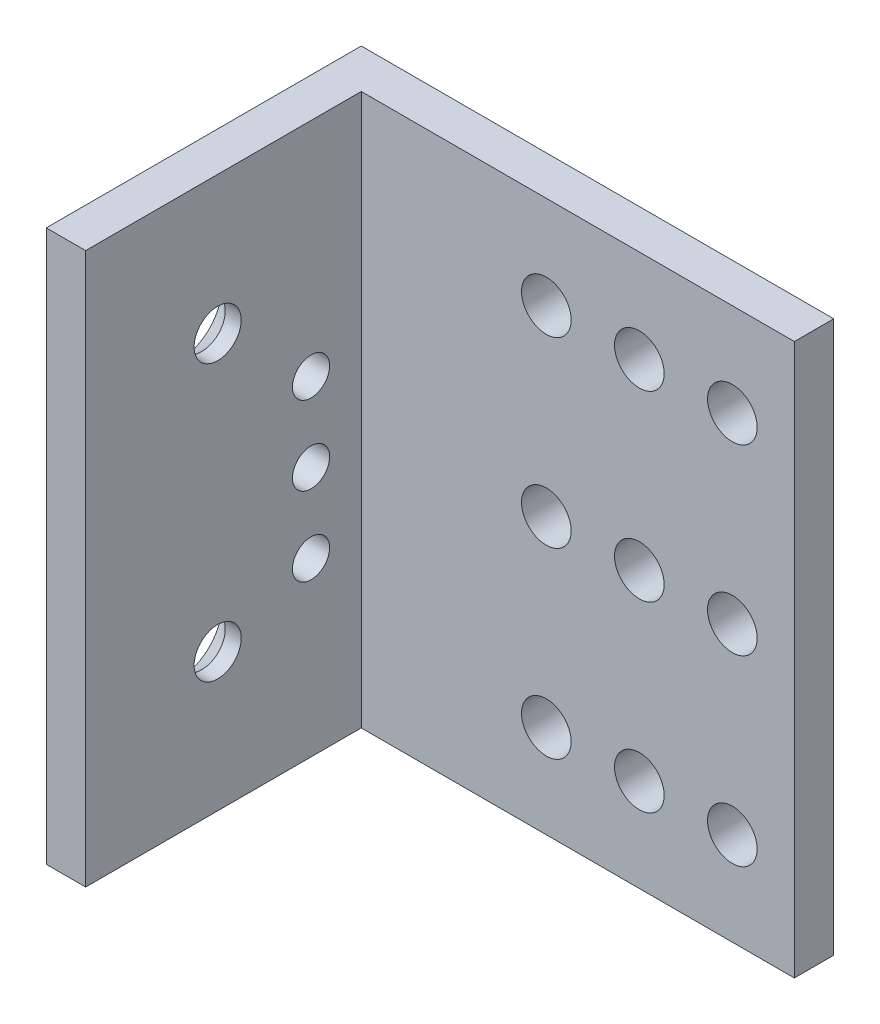
from build123d import *

# Parameters (mm, degrees)
BOSS_EXTRUDE1_DEPTH                            = 22.225
CSK_FOR_6_FLAT_HEAD_MACHINE_SCREW1_D           = 3.7973
CSK_FOR_6_FLAT_HEAD_MACHINE_SCREW1_CSINK_D     = 7.0866
CSK_FOR_6_FLAT_HEAD_MACHINE_SCREW1_CSINK_ANGLE = 82
SKETCH6_R                                      = 2
CUT_EXTRUDE2_DEPTH                             = 26.4
SKETCH7_R                                      = 1.5
CUT_EXTRUDE3_DEPTH                             = 4.175


with BuildPart() as part:
    # Sketch1 → Boss-Extrude1 (new body, symmetric)
    with BuildSketch(Plane(origin=(0, 0, 0), x_dir=(1, 0, 0), z_dir=(0, 1, 0))):
        Polygon((-19.05, -12.7), (-15.875, -12.7), (-15.875, 9.525), (19.05, 9.525), (19.05, 12.7), (-19.05, 12.7), align=None)
    extrude(amount=BOSS_EXTRUDE1_DEPTH, both=True)

    # CSK for #6 Flat Head Machine Screw1 (through all)
    with Locations(Plane.ZY.offset(19.05)):
        with Locations((2.055, 11.1125)):
            csk_for_6_flat_head_machine_screw1 = CounterSinkHole(CSK_FOR_6_FLAT_HEAD_MACHINE_SCREW1_D / 2, CSK_FOR_6_FLAT_HEAD_MACHINE_SCREW1_CSINK_D / 2, counter_sink_angle=CSK_FOR_6_FLAT_HEAD_MACHINE_SCREW1_CSINK_ANGLE)

    # Sketch6 → Cut-Extrude2 (cut, through all)
    with BuildSketch(Plane(origin=(0, 0, -12.7), x_dir=(-1, 0, 0), z_dir=(0, 0, -1))):
        with Locations((-14.05, -14.725)):
            Circle(SKETCH6_R)
        with Locations((-6.55, -14.725)):
            Circle(SKETCH6_R)
        with Locations((-6.55, 0)):
            Circle(SKETCH6_R)
        with Locations((-6.55, 14.725)):
            Circle(SKETCH6_R)
        with Locations((-14.05, 0)):
            Circle(SKETCH6_R)
        with Locations((-14.05, 14.725)):
            Circle(SKETCH6_R)
        with Locations((0.95, -14.725)):
            Circle(SKETCH6_R)
        with Locations((0.95, 0)):
            Circle(SKETCH6_R)
        with Locations((0.95, 14.725)):
            Circle(SKETCH6_R)
    extrude(amount=-CUT_EXTRUDE2_DEPTH, mode=Mode.SUBTRACT)

    # Mirror1: CSK for #6 Flat Head Machine Screw1 across plane
    add(csk_for_6_flat_head_machine_screw1.mirror(Plane.ZX), mode=Mode.SUBTRACT)

    # Sketch7 → Cut-Extrude3 (cut, through all)
    with BuildSketch(Plane(origin=(-15.875, 0, 0), x_dir=(0, 0, -1), z_dir=(1, 0, 0))):
        with Locations((5.475, -2)):
            Circle(SKETCH7_R)
        with Locations((5.475, -8.35)):
            Circle(SKETCH7_R)
        with Locations((5.475, 4.35)):
            Circle(SKETCH7_R)
    extrude(amount=-CUT_EXTRUDE3_DEPTH, mode=Mode.SUBTRACT)


solid = part.part
